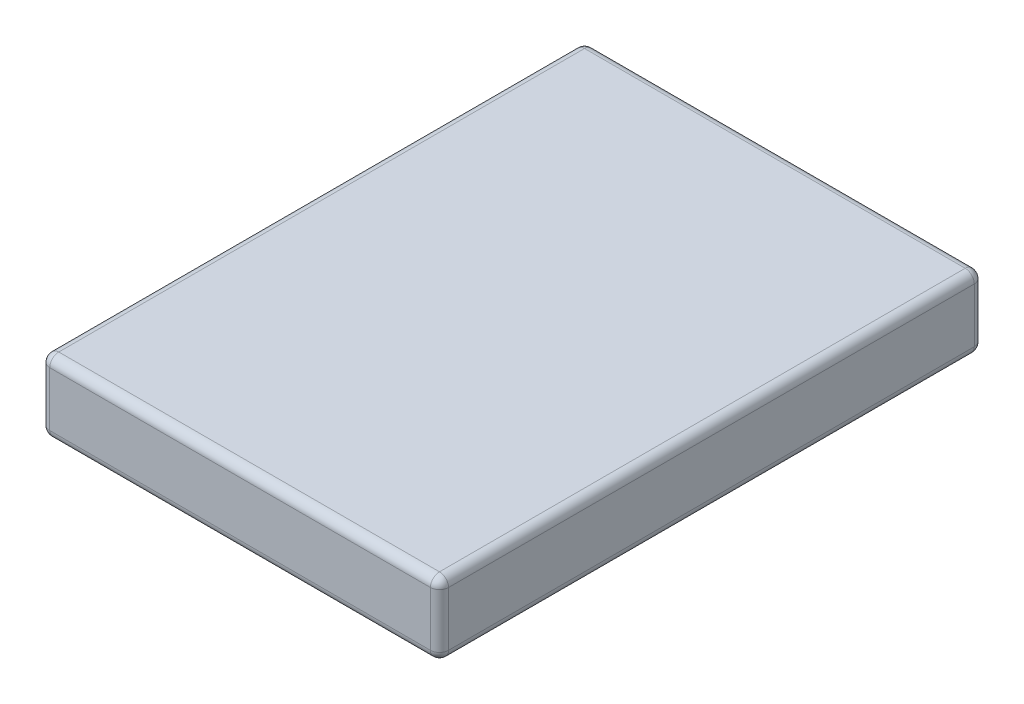
from build123d import *

# Parameters (mm, degrees)
ESQUISSE1_W        = 11
ESQUISSE1_H        = 15
BOSS_EXTRU_1_DEPTH = 2
CONG_1_R           = 0.25


with BuildPart() as part:
    # Esquisse1 → Boss.-Extru.1 (new body)
    with BuildSketch(Plane(origin=(0, 0, 0), x_dir=(1, 0, 0), z_dir=(0, 1, 0))):
        Rectangle(ESQUISSE1_W, ESQUISSE1_H)
    extrude(amount=BOSS_EXTRU_1_DEPTH)

    # Congé1
    cong_1_edges = [part.edges().sort_by_distance(p)[0] for p in [
        (5.5, 2, 0),
        (0, 2, -7.5),
        (-5.5, 2, 0),
        (0, 0, -7.5),
        (5.5, 0, 0),
        (0, 0, 7.5),
        (-5.5, 0, 0),
        (-5.5, 1, -7.5),
        (5.5, 1, -7.5),
        (5.5, 1, 7.5),
        (-5.5, 1, 7.5),
        (0, 2, 7.5),
    ]]
    fillet(cong_1_edges, radius=CONG_1_R)


solid = part.part
